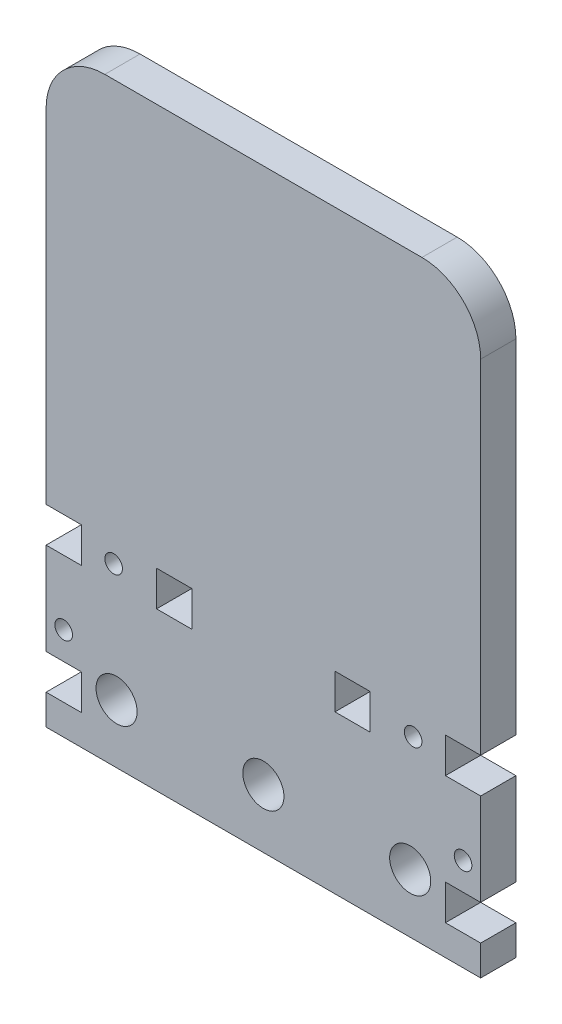
from build123d import *

# Parameters (mm, degrees)
SKETCH1_R           = 3.5
SKETCH1_W           = 6
SKETCH1_H           = 6
BOSS_EXTRUDE1_DEPTH = 6
CUT_EXTRUDE1_REACH  = 8
SKETCH2_R           = 1.5


with BuildPart() as part:
    # Sketch1 → Boss-Extrude1 (new body)
    with BuildSketch(Plane.XY):
        with BuildLine():
            Line((0, 5.15), (0, 0))
            Line((0, 0), (74, 0))
            Line((74, 0), (74, 5.15))
            Line((74, 5.15), (68, 5.15))
            Line((68, 5.15), (68, 11.15))
            Line((68, 11.15), (74, 11.15))
            Line((74, 11.15), (74, 26.84))
            Line((74, 26.84), (68, 26.84))
            Line((68, 26.84), (68, 32.84))
            Line((68, 32.84), (74, 32.84))
            Line((74, 32.84), (74, 91.26))
            ThreePointArc((74, 91.26), (71.071067812, 98.331067812), (64, 101.26))
            Line((64, 101.26), (10, 101.26))
            ThreePointArc((10, 101.26), (2.928932188, 98.331067812), (0, 91.26))
            Line((0, 91.26), (0, 32.84))
            Line((0, 32.84), (6, 32.84))
            Line((6, 32.84), (6, 26.84))
            Line((6, 26.84), (0, 26.84))
            Line((0, 26.84), (0, 11.15))
            Line((0, 11.15), (6, 11.15))
            Line((6, 11.15), (6, 5.15))
            Line((6, 5.15), (0, 5.15))
        make_face()
        with Locations((12, 10)):
            Circle(SKETCH1_R, mode=Mode.SUBTRACT)
        with Locations((21.81, 29.84)):
            Rectangle(SKETCH1_W, SKETCH1_H, mode=Mode.SUBTRACT)
        with Locations((37, 10)):
            Circle(SKETCH1_R, mode=Mode.SUBTRACT)
        with Locations((62, 10)):
            Circle(SKETCH1_R, mode=Mode.SUBTRACT)
        with Locations((52.19, 29.84)):
            Rectangle(SKETCH1_W, SKETCH1_H, mode=Mode.SUBTRACT)
    extrude(amount=BOSS_EXTRUDE1_DEPTH)

    # Sketch2 → Cut-Extrude1 (cut, up to next)
    with BuildSketch(Plane.XY.offset(6), mode=Mode.PRIVATE) as cut_extrude1_sk1:
        with Locations((3, 15.84)):
            Circle(SKETCH2_R)
    cut_extrude1_tool1 = extrude(cut_extrude1_sk1.sketch, amount=-CUT_EXTRUDE1_REACH, mode=Mode.PRIVATE) & part.part
    add(cut_extrude1_tool1.solids().sort_by_distance((3, 15.84, 6))[0], mode=Mode.SUBTRACT)
    # Sketch2 → Cut-Extrude1 (cut, up to next)
    with BuildSketch(Plane.XY.offset(6), mode=Mode.PRIVATE) as cut_extrude1_sk2:
        with Locations((11.5, 29.84)):
            Circle(SKETCH2_R)
    cut_extrude1_tool2 = extrude(cut_extrude1_sk2.sketch, amount=-CUT_EXTRUDE1_REACH, mode=Mode.PRIVATE) & part.part
    add(cut_extrude1_tool2.solids().sort_by_distance((11.5, 29.84, 6))[0], mode=Mode.SUBTRACT)
    # Sketch2 → Cut-Extrude1 (cut, up to next)
    with BuildSketch(Plane.XY.offset(6), mode=Mode.PRIVATE) as cut_extrude1_sk3:
        with Locations((62.5, 29.84)):
            Circle(SKETCH2_R)
    cut_extrude1_tool3 = extrude(cut_extrude1_sk3.sketch, amount=-CUT_EXTRUDE1_REACH, mode=Mode.PRIVATE) & part.part
    add(cut_extrude1_tool3.solids().sort_by_distance((62.5, 29.84, 6))[0], mode=Mode.SUBTRACT)
    # Sketch2 → Cut-Extrude1 (cut, up to next)
    with BuildSketch(Plane.XY.offset(6), mode=Mode.PRIVATE) as cut_extrude1_sk4:
        with Locations((71, 15.84)):
            Circle(SKETCH2_R)
    cut_extrude1_tool4 = extrude(cut_extrude1_sk4.sketch, amount=-CUT_EXTRUDE1_REACH, mode=Mode.PRIVATE) & part.part
    add(cut_extrude1_tool4.solids().sort_by_distance((71, 15.84, 6))[0], mode=Mode.SUBTRACT)


solid = part.part
